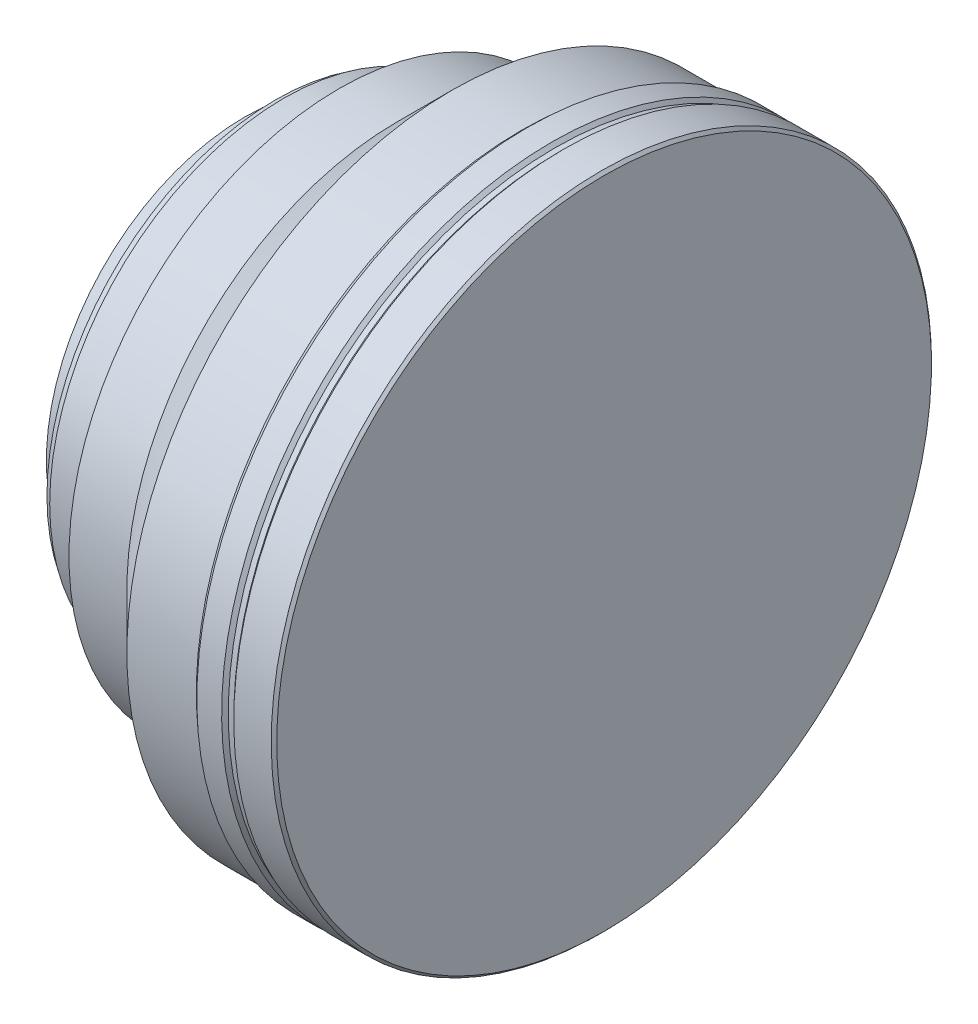
from build123d import *

# Parameters (mm, degrees)
CHAMFER1_SIZE = 0.5


with BuildPart() as part:
    # Sketch1 → Revolve1 (revolve)
    with BuildSketch(Plane.XY):
        Polygon((0, 0), (0, 59.9), (-7.3, 59.9), (-7.9, 59.3), (-8.9, 59.3), (-9.5, 59.9), (-14, 59.9), (-15, 59), (-27.6, 59), (-37.6, 49), (-48.1, 49), (-48.1, 45.25), (-48.8, 45.25), (-48.8, 41.5), (-50.8, 41.5), (-50.8, 42.5), (-58.1, 42.5), (-58.1, 41.5), (-59.6, 41.5), (-59.6, 36), (-65.2, 36), (-65.2, 32), (-66.2, 32), (-66.2, 0), align=None)
    revolve(axis=Axis((0, 0, 0), (-1, 0, 0)))

    # Chamfer1
    chamfer1_edges = [part.edges().sort_by_distance(p)[0] for p in [
        (0, -59.9, 0),
    ]]
    chamfer(chamfer1_edges, length=CHAMFER1_SIZE)


solid = part.part
